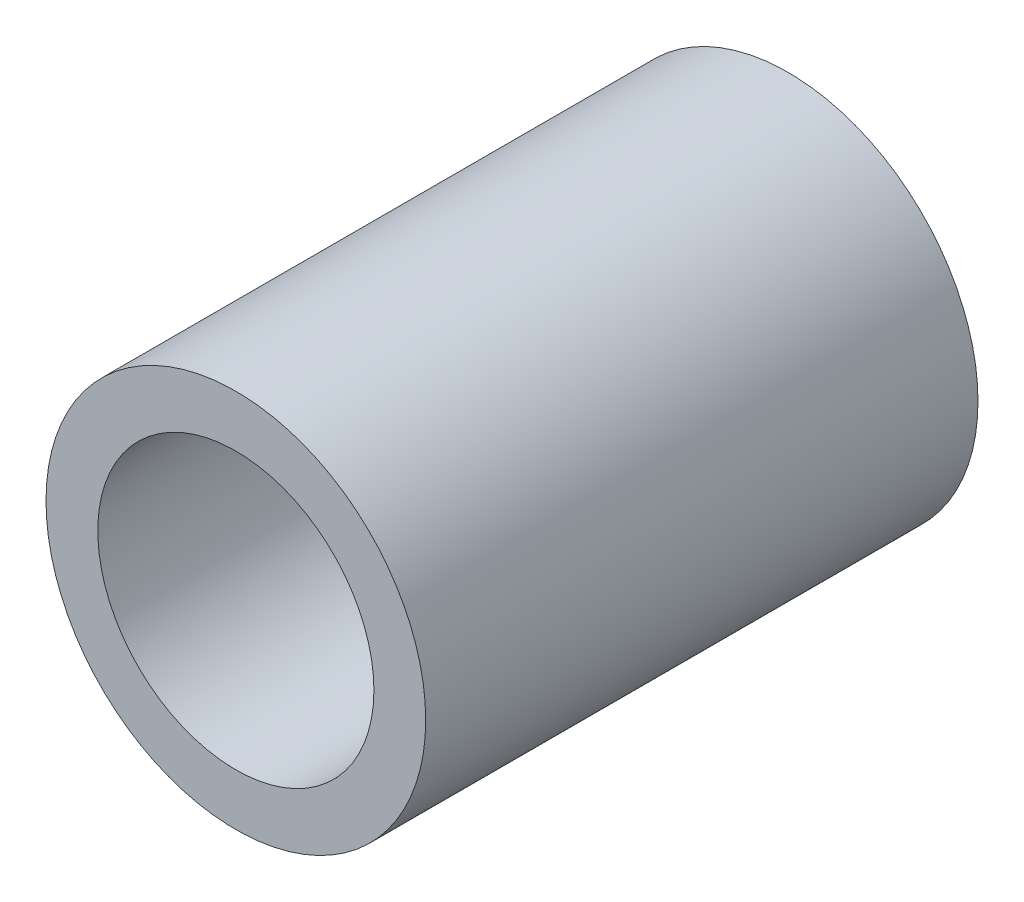
from build123d import *

# Parameters (mm, degrees)
ESBO_O1_R                = 2.75
ESBO_O1_R_2              = 2
RESSALTO_EXTRUS_O1_DEPTH = 8


with BuildPart() as part:
    # Esboço1 → Ressalto-extrusão1 (new body)
    with BuildSketch(Plane.XY):
        Circle(ESBO_O1_R)
        Circle(ESBO_O1_R_2, mode=Mode.SUBTRACT)
    extrude(amount=RESSALTO_EXTRUS_O1_DEPTH)


solid = part.part
